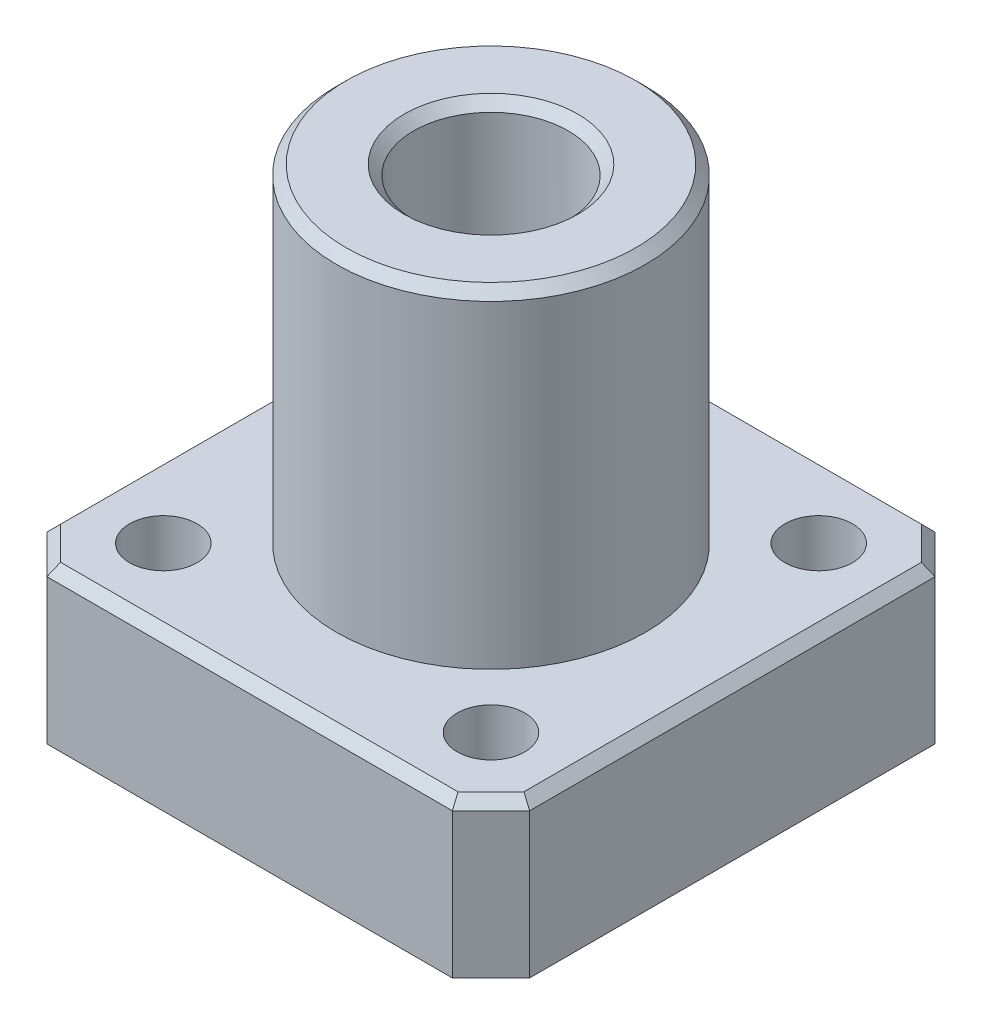
from build123d import *

# Parameters (mm, degrees)
ESQUISSE1_W      = 25
ESQUISSE1_H      = 25
ESQUISSE1_R      = 1.75
EXTRUSION1_DEPTH = 8
ESQUISSE2_R      = 8
EXTRUSION2_DEPTH = 17
CHANFREIN1_SIZE  = 2
EXTRUSION3_REACH = 27
ESQUISSE3_R      = 4
CHANFREIN2_SIZE  = 0.5


with BuildPart() as part:
    # Esquisse1 → Extrusion1 (new body)
    with BuildSketch(Plane(origin=(0, 0, 0), x_dir=(1, 0, 0), z_dir=(0, 1, 0))):
        with Locations((12.5, 12.5)):
            Rectangle(ESQUISSE1_W, ESQUISSE1_H)
        with Locations((4.014718626, 20.985281374)):
            Circle(ESQUISSE1_R, mode=Mode.SUBTRACT)
        with Locations((20.985281374, 20.985281374)):
            Circle(ESQUISSE1_R, mode=Mode.SUBTRACT)
        with Locations((20.985281374, 4.014718626)):
            Circle(ESQUISSE1_R, mode=Mode.SUBTRACT)
        with Locations((4.014718626, 4.014718626)):
            Circle(ESQUISSE1_R, mode=Mode.SUBTRACT)
    extrude(amount=EXTRUSION1_DEPTH)

    # Esquisse2 → Extrusion2 (add)
    with BuildSketch(Plane(origin=(0, 8, 0), x_dir=(1, 0, 0), z_dir=(0, 1, 0))):
        with Locations((12.5, 12.5)):
            Circle(ESQUISSE2_R)
    extrude(amount=EXTRUSION2_DEPTH)

    # Chanfrein1
    chanfrein1_edges = [part.edges().sort_by_distance(p)[0] for p in [
        (0, 4, -25),
        (25, 4, -25),
        (25, 4, 0),
        (0, 4, 0),
    ]]
    chamfer(chanfrein1_edges, length=CHANFREIN1_SIZE)

    # Esquisse3 → Extrusion3 (cut, up to next)
    with BuildSketch(Plane(origin=(0, 25, 0), x_dir=(1, 0, 0), z_dir=(0, 1, 0)), mode=Mode.PRIVATE) as extrusion3_sk1:
        with Locations((12.5, 12.5)):
            Circle(ESQUISSE3_R)
    extrusion3_tool1 = extrude(extrusion3_sk1.sketch, amount=-EXTRUSION3_REACH, mode=Mode.PRIVATE) & part.part
    add(extrusion3_tool1.solids().sort_by_distance((12.5, 25, -12.5))[0], mode=Mode.SUBTRACT)

    # Chanfrein2
    chanfrein2_edges = [part.edges().sort_by_distance(p)[0] for p in [
        (4.5, 25, -12.5),
        (0, 8, -12.5),
        (12.5, 8, -25),
        (12.5, 8, 0),
        (25, 8, -12.5),
        (1, 8, -1),
        (24, 8, -1),
        (24, 8, -24),
        (1, 8, -24),
        (8.5, 0, -12.5),
        (8.5, 25, -12.5),
    ]]
    chamfer(chanfrein2_edges, length=CHANFREIN2_SIZE)


solid = part.part
